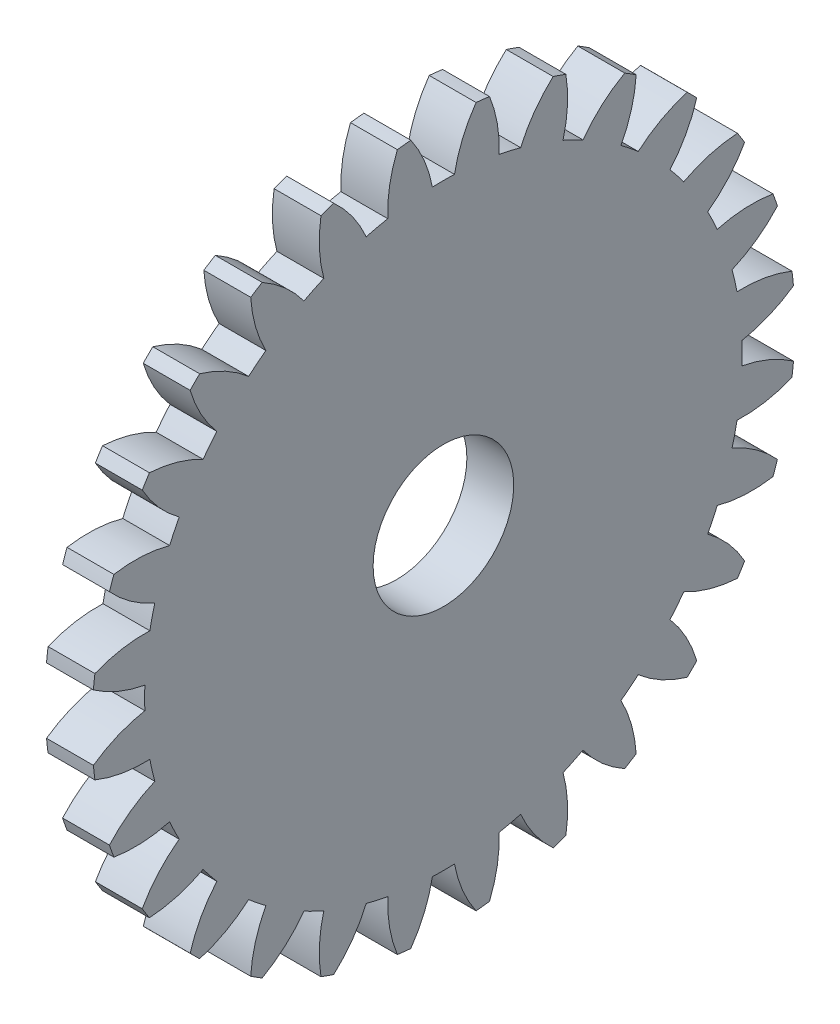
from build123d import *

# Parameters (mm, degrees)
BASPROSKE_W     = 2
BASPROSKE_H     = 15
TOOTHCUT_DEPTH  = 22.307275753
TEETHCUTS_COUNT = 28
TEETHCUTS_ANGLE = 347.142857143
BORSKE_R        = 3
BORE_DEPTH      = 50.0000508


with BuildPart() as part:
    # BasProSke → Base-Revolve (revolve)
    with BuildSketch(Plane(origin=(0, 0, 0), x_dir=(1, 0, 0), z_dir=(0, 1, 0)), mode=Mode.PRIVATE) as base_revolve_sk:
        with Locations((1, 7.5)):
            Rectangle(BASPROSKE_W, BASPROSKE_H)
    revolve(base_revolve_sk.sketch.rotate(Axis((-10, 0, 0), (1, 0, 0)), 180), axis=Axis((-10, 0, 0), (1, 0, 0)))

    # TooCutSke → ToothCut (cut, through all)
    with BuildSketch(Plane(origin=(0, 0, 0), x_dir=(0, 0, -1), z_dir=(1, 0, 0))):
        with BuildLine():
            ThreePointArc((0.471336039, 12.740284272), (0, 12.749), (-0.471336039, 12.740284272))
            ThreePointArc((-0.471336039, 12.740284272), (-0.81983923, 13.900763331), (-1.409805137, 14.959114099))
            ThreePointArc((-1.409805137, 14.959114099), (0, 15.0254), (1.409805137, 14.959114099))
            ThreePointArc((1.409805137, 14.959114099), (0.81983923, 13.900763331), (0.471336039, 12.740284272))
        make_face()
    toothcut = extrude(amount=TOOTHCUT_DEPTH, mode=Mode.SUBTRACT)

    # TeethCuts: ToothCut ×28 about axis
    teethcuts_axis = Axis((-10, 0, 0), (1, 0, 0))
    for i in range(1, TEETHCUTS_COUNT):
        add(toothcut.rotate(teethcuts_axis, i * TEETHCUTS_ANGLE / (TEETHCUTS_COUNT - 1)), mode=Mode.SUBTRACT)

    # BorSke → Bore (cut, symmetric)
    with BuildSketch(Plane(origin=(0, 0, 0), x_dir=(0, 0, -1), z_dir=(1, 0, 0))):
        with Locations(Location((0, 0, 0), (0, 0, 180))):
            Circle(BORSKE_R)
    extrude(amount=BORE_DEPTH, both=True, mode=Mode.SUBTRACT)


solid = part.part
